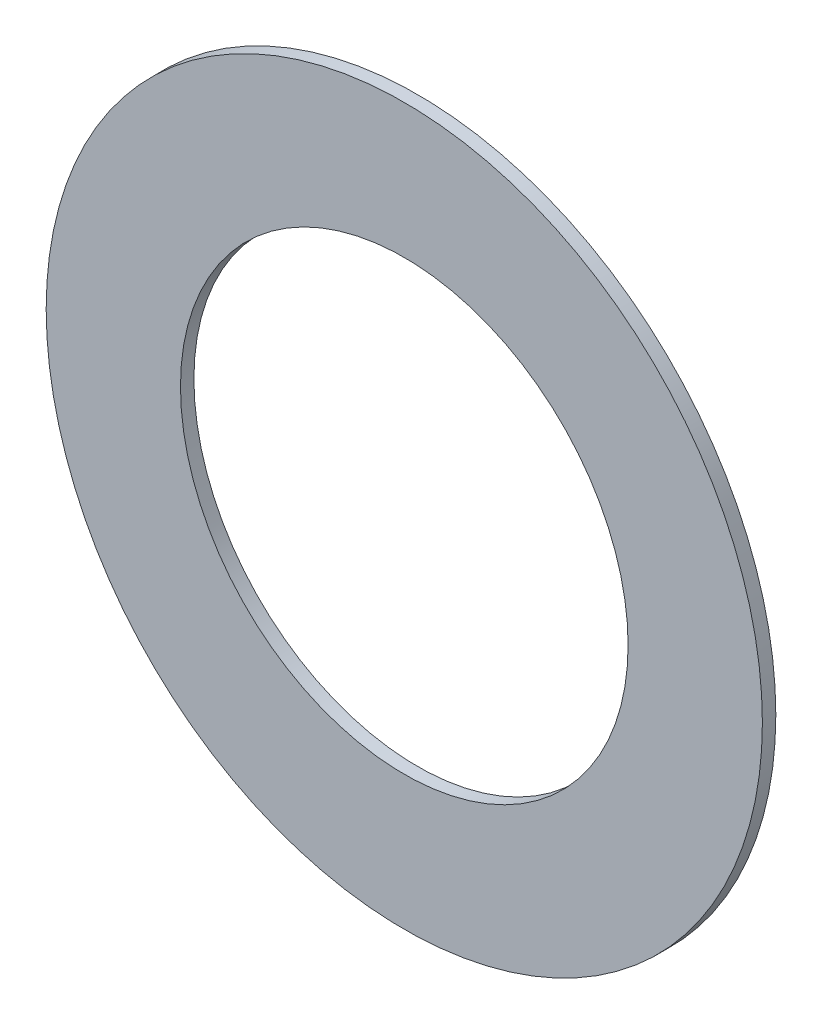
from build123d import *

# Parameters (mm, degrees)
SKETCH1_R           = 8
SKETCH1_R_2         = 5
BOSS_EXTRUDE1_DEPTH = 0.3


with BuildPart() as part:
    # Sketch1 → Boss-Extrude1 (new body)
    with BuildSketch(Plane.XY):
        Circle(SKETCH1_R)
        Circle(SKETCH1_R_2, mode=Mode.SUBTRACT)
    extrude(amount=BOSS_EXTRUDE1_DEPTH)


solid = part.part
